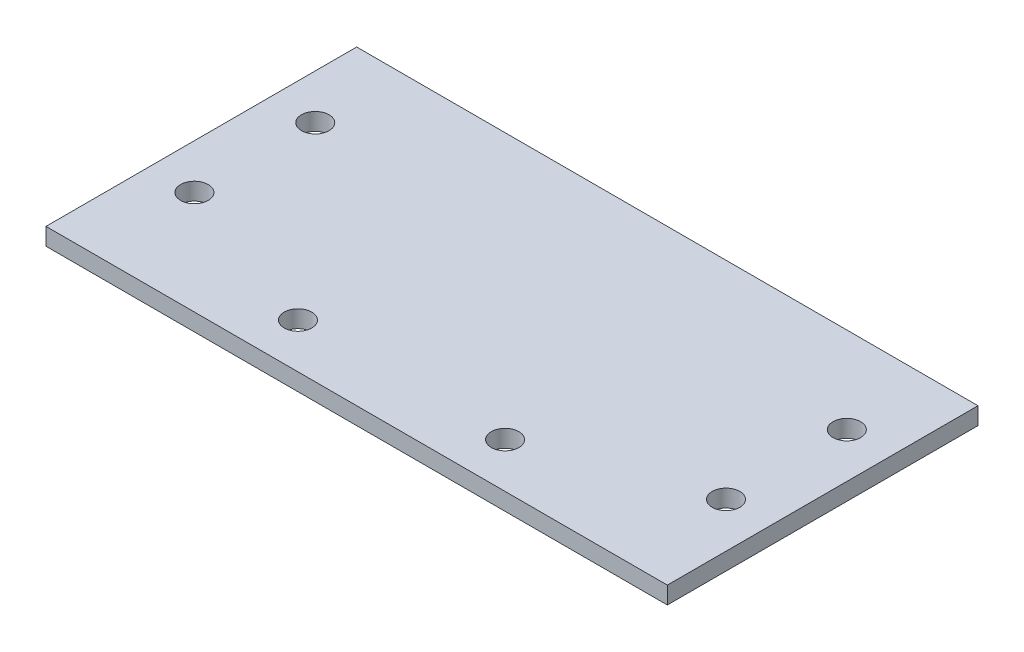
from build123d import *

# Parameters (mm, degrees)
SKETCH1_W             = 180
SKETCH1_H             = 90
BOSS_EXTRUDE1_DEPTH   = 5
F_1_0MM_DOWEL_HOLE1_D = 8


with BuildPart() as part:
    # Sketch1 → Boss-Extrude1 (new body)
    with BuildSketch(Plane(origin=(0, 0, 0), x_dir=(1, 0, 0), z_dir=(0, 1, 0))):
        Rectangle(SKETCH1_W, SKETCH1_H)
    extrude(amount=BOSS_EXTRUDE1_DEPTH)

    # Ø1.0mm Dowel Hole1 (through all)
    with Locations(Plane(origin=(0, 5, 0), x_dir=(1, 0, 0), z_dir=(0, 1, 0))):
        with Locations((-77, 20), (-77, -15), (-30, -32), (30, -32), (77, -15), (77, 20)):
            Hole(F_1_0MM_DOWEL_HOLE1_D / 2)


solid = part.part
